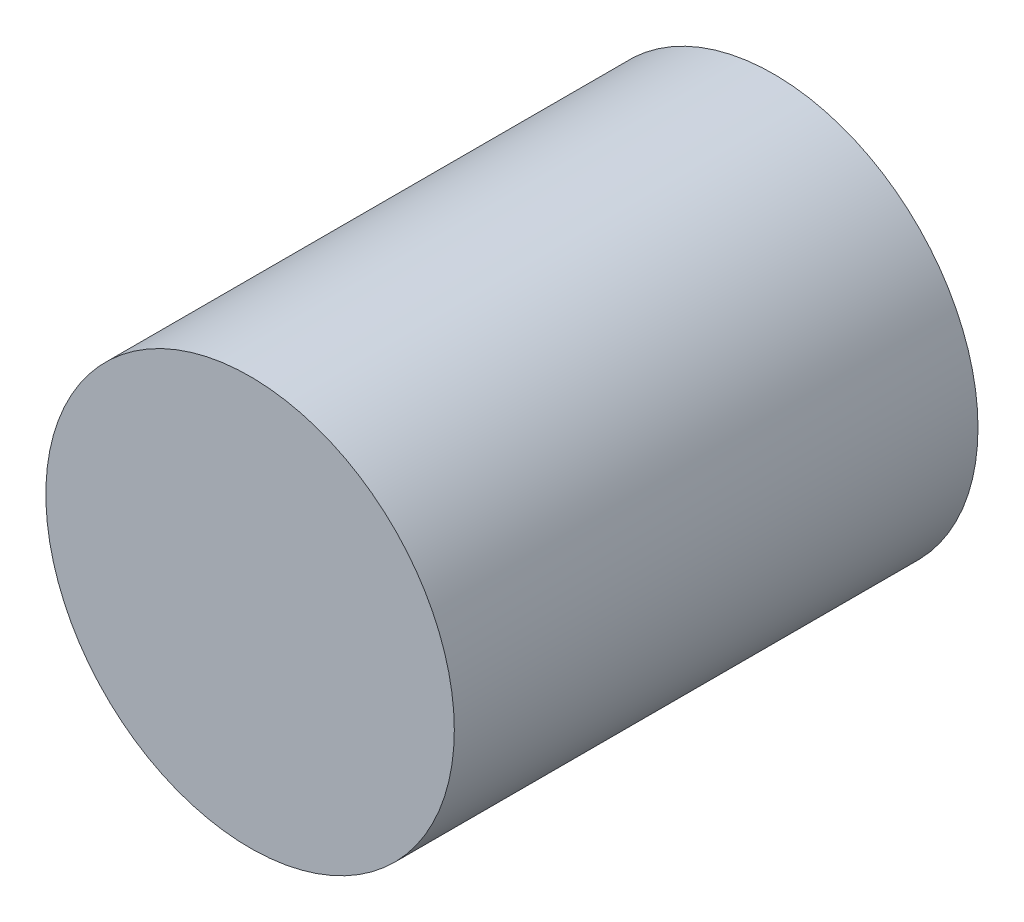
from build123d import *

# Parameters (mm, degrees)
SKETCH1_R           = 9.906
BOSS_EXTRUDE1_DEPTH = 25.4


with BuildPart() as part:
    # Sketch1 → Boss-Extrude1 (new body)
    with BuildSketch(Plane.XY):
        Circle(SKETCH1_R)
    extrude(amount=BOSS_EXTRUDE1_DEPTH)


solid = part.part
